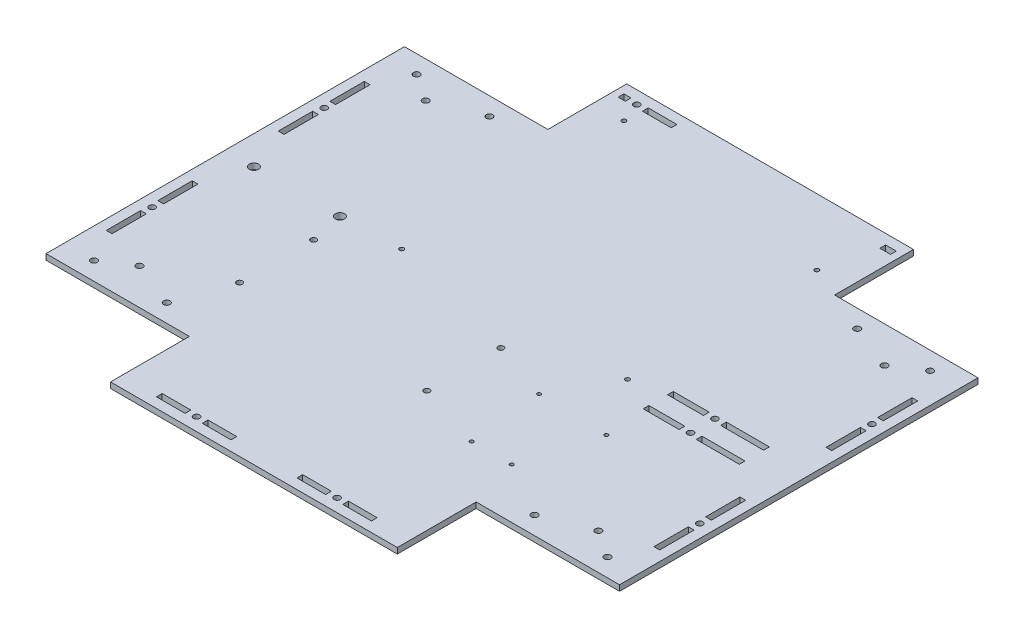
from build123d import *

# Parameters (mm, degrees)
SKETCH1_W                = 400
SKETCH1_H                = 360
BOSS_EXTRUDE1_DEPTH      = 4
SKETCH2_W                = 100
SKETCH2_H                = 55
CORNER_DEPTH             = 4
SKETCH3_R                = 2.25
MOTOR_MOUNTING_DEPTH     = 4
MIRROR2_COPY_1_SKETCH_W  = 100
MIRROR2_COPY_1_SKETCH_H  = 55
MIRROR2_COPY_1_DEPTH     = 4
MIRROR2_COPY_2_SKETCH_R  = 2.25
MIRROR2_COPY_2_DEPTH     = 4
PC_MOUNTING_REACH        = 6
SKETCH5_R                = 1.5
ARDUINO_MOUNTING_REACH   = 6
SKETCH6_R                = 1.25
DCDC_USB_MOUNTING_REACH  = 6
SKETCH7_R                = 2
SKETCH10_W               = 20
SKETCH10_H               = 4
SKETCH10_W_2             = 4
SKETCH10_H_2             = 24
SKETCH10_W_3             = 5
SKETCH10_W_4             = 7.47
SIDES_MOUNTING_DEPTH     = 5
SKETCH11_W               = 30
SKETCH11_H               = 4
SKETCH11_W_2             = 25
FIN_MOUNTING_DEPTH       = 5
M4_CLEARANCE_HOLE1_D     = 4.3
M4_CLEARANCE_HOLE1_DEPTH = 6
M4_CLEARANCE_HOLE1_TIP   = 1.291850331
M6_CLEARANCE_HOLE1_D     = 6.4
M6_CLEARANCE_HOLE1_DEPTH = 6
M6_CLEARANCE_HOLE1_TIP   = 1.922753981


with BuildPart() as part:
    # Sketch1 → Boss-Extrude1 (new body)
    with BuildSketch(Plane(origin=(0, 0, 0), x_dir=(1, 0, 0), z_dir=(0, 1, 0))):
        Rectangle(SKETCH1_W, SKETCH1_H)
    extrude(amount=BOSS_EXTRUDE1_DEPTH)

    # Sketch2 → Corner (cut)
    with BuildSketch(Plane(origin=(0, 4, 0), x_dir=(1, 0, 0), z_dir=(0, 1, 0))):
        with Locations((-150, 152.5)):
            Rectangle(SKETCH2_W, SKETCH2_H)
    corner = extrude(amount=-CORNER_DEPTH, mode=Mode.SUBTRACT)

    # Sketch3 → Motor mounting (cut)
    with BuildSketch(Plane(origin=(0, 4, 0), x_dir=(1, 0, 0), z_dir=(0, 1, 0))):
        with Locations((-179.05, 112.5)):
            Circle(SKETCH3_R)
        with Locations((-128.25, 112.5)):
            Circle(SKETCH3_R)
        with Locations((-160, 99.8)):
            Circle(SKETCH3_R)
    motor_mounting = extrude(amount=-MOTOR_MOUNTING_DEPTH, mode=Mode.SUBTRACT)

    # Mirror1: Corner, Motor mounting across plane
    add(corner.mirror(Plane.XY), mode=Mode.SUBTRACT)
    add(motor_mounting.mirror(Plane.XY), mode=Mode.SUBTRACT)

    # Mirror2: Corner, Motor mounting across plane
    add(corner.mirror(Plane(origin=(0, 0, 0), x_dir=(0, 0, 1), z_dir=(1, 0, 0))), mode=Mode.SUBTRACT)
    add(motor_mounting.mirror(Plane(origin=(0, 0, 0), x_dir=(0, 0, 1), z_dir=(1, 0, 0))), mode=Mode.SUBTRACT)

    # Mirror2 copy 1 sketch → Mirror2 copy 1 (cut)
    with BuildSketch(Plane(origin=(0, 4, 0), x_dir=(-1, 0, 0), z_dir=(0, 1, 0))):
        with Locations((-150, 152.5)):
            Rectangle(MIRROR2_COPY_1_SKETCH_W, MIRROR2_COPY_1_SKETCH_H)
    extrude(amount=-MIRROR2_COPY_1_DEPTH, mode=Mode.SUBTRACT)

    # Mirror2 copy 2 sketch → Mirror2 copy 2 (cut)
    with BuildSketch(Plane(origin=(0, 4, 0), x_dir=(-1, 0, 0), z_dir=(0, 1, 0))):
        with Locations((-179.05, 112.5)):
            Circle(MIRROR2_COPY_2_SKETCH_R)
        with Locations((-128.25, 112.5)):
            Circle(MIRROR2_COPY_2_SKETCH_R)
        with Locations((-160, 99.8)):
            Circle(MIRROR2_COPY_2_SKETCH_R)
    extrude(amount=-MIRROR2_COPY_2_DEPTH, mode=Mode.SUBTRACT)

    # Sketch5 → PC mounting (cut, up to next)
    with BuildSketch(Plane(origin=(0, 4, 0), x_dir=(1, 0, 0), z_dir=(0, 1, 0)), mode=Mode.PRIVATE) as pc_mounting_sk1:
        with Locations((-78.74, 156.73)):
            Circle(SKETCH5_R)
    pc_mounting_tool1 = extrude(pc_mounting_sk1.sketch, amount=-PC_MOUNTING_REACH, mode=Mode.PRIVATE) & part.part
    add(pc_mounting_tool1.solids().sort_by_distance((-78.74, 4, -156.73))[0], mode=Mode.SUBTRACT)
    # Sketch5 → PC mounting (cut, up to next)
    with BuildSketch(Plane(origin=(0, 4, 0), x_dir=(1, 0, 0), z_dir=(0, 1, 0)), mode=Mode.PRIVATE) as pc_mounting_sk2:
        with Locations((78.74, 133.87)):
            Circle(SKETCH5_R)
    pc_mounting_tool2 = extrude(pc_mounting_sk2.sketch, amount=-PC_MOUNTING_REACH, mode=Mode.PRIVATE) & part.part
    add(pc_mounting_tool2.solids().sort_by_distance((78.74, 4, -133.87))[0], mode=Mode.SUBTRACT)
    # Sketch5 → PC mounting (cut, up to next)
    with BuildSketch(Plane(origin=(0, 4, 0), x_dir=(1, 0, 0), z_dir=(0, 1, 0)), mode=Mode.PRIVATE) as pc_mounting_sk3:
        with Locations((-78.74, 1.79)):
            Circle(SKETCH5_R)
    pc_mounting_tool3 = extrude(pc_mounting_sk3.sketch, amount=-PC_MOUNTING_REACH, mode=Mode.PRIVATE) & part.part
    add(pc_mounting_tool3.solids().sort_by_distance((-78.74, 4, -1.79))[0], mode=Mode.SUBTRACT)
    # Sketch5 → PC mounting (cut, up to next)
    with BuildSketch(Plane(origin=(0, 4, 0), x_dir=(1, 0, 0), z_dir=(0, 1, 0)), mode=Mode.PRIVATE) as pc_mounting_sk4:
        with Locations((78.74, 1.79)):
            Circle(SKETCH5_R)
    pc_mounting_tool4 = extrude(pc_mounting_sk4.sketch, amount=-PC_MOUNTING_REACH, mode=Mode.PRIVATE) & part.part
    add(pc_mounting_tool4.solids().sort_by_distance((78.74, 4, -1.79))[0], mode=Mode.SUBTRACT)

    # Sketch6 → Arduino mounting (cut, up to next)
    with BuildSketch(Plane(origin=(0, 4, 0), x_dir=(1, 0, 0), z_dir=(0, 1, 0)), mode=Mode.PRIVATE) as arduino_mounting_sk1:
        with Locations((56.8, -37.9)):
            Circle(SKETCH6_R)
    arduino_mounting_tool1 = extrude(arduino_mounting_sk1.sketch, amount=-ARDUINO_MOUNTING_REACH, mode=Mode.PRIVATE) & part.part
    add(arduino_mounting_tool1.solids().sort_by_distance((56.8, 4, 37.9))[0], mode=Mode.SUBTRACT)
    # Sketch6 → Arduino mounting (cut, up to next)
    with BuildSketch(Plane(origin=(0, 4, 0), x_dir=(1, 0, 0), z_dir=(0, 1, 0)), mode=Mode.PRIVATE) as arduino_mounting_sk2:
        with Locations((105, -39.2)):
            Circle(SKETCH6_R)
    arduino_mounting_tool2 = extrude(arduino_mounting_sk2.sketch, amount=-ARDUINO_MOUNTING_REACH, mode=Mode.PRIVATE) & part.part
    add(arduino_mounting_tool2.solids().sort_by_distance((105, 4, 39.2))[0], mode=Mode.SUBTRACT)
    # Sketch6 → Arduino mounting (cut, up to next)
    with BuildSketch(Plane(origin=(0, 4, 0), x_dir=(1, 0, 0), z_dir=(0, 1, 0)), mode=Mode.PRIVATE) as arduino_mounting_sk3:
        with Locations((89.8, -90)):
            Circle(SKETCH6_R)
    arduino_mounting_tool3 = extrude(arduino_mounting_sk3.sketch, amount=-ARDUINO_MOUNTING_REACH, mode=Mode.PRIVATE) & part.part
    add(arduino_mounting_tool3.solids().sort_by_distance((89.8, 4, 90))[0], mode=Mode.SUBTRACT)
    # Sketch6 → Arduino mounting (cut, up to next)
    with BuildSketch(Plane(origin=(0, 4, 0), x_dir=(1, 0, 0), z_dir=(0, 1, 0)), mode=Mode.PRIVATE) as arduino_mounting_sk4:
        with Locations((61.9, -90)):
            Circle(SKETCH6_R)
    arduino_mounting_tool4 = extrude(arduino_mounting_sk4.sketch, amount=-ARDUINO_MOUNTING_REACH, mode=Mode.PRIVATE) & part.part
    add(arduino_mounting_tool4.solids().sort_by_distance((61.9, 4, 90))[0], mode=Mode.SUBTRACT)

    # Sketch7 → DCDC-USB mounting (cut, up to next)
    with BuildSketch(Plane(origin=(0, 4, 0), x_dir=(1, 0, 0), z_dir=(0, 1, 0)), mode=Mode.PRIVATE) as dcdc_usb_mounting_sk1:
        with Locations((-115, -75)):
            Circle(SKETCH7_R)
    dcdc_usb_mounting_tool1 = extrude(dcdc_usb_mounting_sk1.sketch, amount=-DCDC_USB_MOUNTING_REACH, mode=Mode.PRIVATE) & part.part
    add(dcdc_usb_mounting_tool1.solids().sort_by_distance((-115, 4, 75))[0], mode=Mode.SUBTRACT)
    # Sketch7 → DCDC-USB mounting (cut, up to next)
    with BuildSketch(Plane(origin=(0, 4, 0), x_dir=(1, 0, 0), z_dir=(0, 1, 0)), mode=Mode.PRIVATE) as dcdc_usb_mounting_sk2:
        with Locations((15.6, -75)):
            Circle(SKETCH7_R)
    dcdc_usb_mounting_tool2 = extrude(dcdc_usb_mounting_sk2.sketch, amount=-DCDC_USB_MOUNTING_REACH, mode=Mode.PRIVATE) & part.part
    add(dcdc_usb_mounting_tool2.solids().sort_by_distance((15.6, 4, 75))[0], mode=Mode.SUBTRACT)
    # Sketch7 → DCDC-USB mounting (cut, up to next)
    with BuildSketch(Plane(origin=(0, 4, 0), x_dir=(1, 0, 0), z_dir=(0, 1, 0)), mode=Mode.PRIVATE) as dcdc_usb_mounting_sk3:
        with Locations((-115, -23.4)):
            Circle(SKETCH7_R)
    dcdc_usb_mounting_tool3 = extrude(dcdc_usb_mounting_sk3.sketch, amount=-DCDC_USB_MOUNTING_REACH, mode=Mode.PRIVATE) & part.part
    add(dcdc_usb_mounting_tool3.solids().sort_by_distance((-115, 4, 23.4))[0], mode=Mode.SUBTRACT)
    # Sketch7 → DCDC-USB mounting (cut, up to next)
    with BuildSketch(Plane(origin=(0, 4, 0), x_dir=(1, 0, 0), z_dir=(0, 1, 0)), mode=Mode.PRIVATE) as dcdc_usb_mounting_sk4:
        with Locations((15.6, -23.4)):
            Circle(SKETCH7_R)
    dcdc_usb_mounting_tool4 = extrude(dcdc_usb_mounting_sk4.sketch, amount=-DCDC_USB_MOUNTING_REACH, mode=Mode.PRIVATE) & part.part
    add(dcdc_usb_mounting_tool4.solids().sort_by_distance((15.6, 4, 23.4))[0], mode=Mode.SUBTRACT)

    # Sketch10 → Sides mounting (cut, through all)
    with BuildSketch(Plane(origin=(0, 4, 0), x_dir=(1, 0, 0), z_dir=(0, 1, 0))):
        with Locations((-68, 171)):
            Rectangle(SKETCH10_W, SKETCH10_H)
        with Locations((-191, 78)):
            Rectangle(SKETCH10_W_2, SKETCH10_H_2)
        with Locations((-191, -42)):
            Rectangle(SKETCH10_W_2, SKETCH10_H_2)
        with Locations((-191, -78)):
            Rectangle(SKETCH10_W_2, SKETCH10_H_2)
        with Locations((-191, 42)):
            Rectangle(SKETCH10_W_2, SKETCH10_H_2)
        with Locations((191, 78)):
            Rectangle(SKETCH10_W_2, SKETCH10_H_2)
        with Locations((191, 42)):
            Rectangle(SKETCH10_W_2, SKETCH10_H_2)
        with Locations((191, -42)):
            Rectangle(SKETCH10_W_2, SKETCH10_H_2)
        with Locations((191, -78)):
            Rectangle(SKETCH10_W_2, SKETCH10_H_2)
        with Locations((-65, -171)):
            Rectangle(SKETCH10_W, SKETCH10_H)
        with Locations((-33, -171)):
            Rectangle(SKETCH10_W, SKETCH10_H)
        with Locations((33, -171)):
            Rectangle(SKETCH10_W, SKETCH10_H)
        with Locations((65, -171)):
            Rectangle(SKETCH10_W, SKETCH10_H)
        with Locations((-92.5, 171)):
            Rectangle(SKETCH10_W_3, SKETCH10_H)
        with Locations((91.265, 171)):
            Rectangle(SKETCH10_W_4, SKETCH10_H)
    extrude(amount=-SIDES_MOUNTING_DEPTH, mode=Mode.SUBTRACT)

    # Sketch11 → fin mounting (cut, through all)
    with BuildSketch(Plane(origin=(0, 4, 0), x_dir=(1, 0, 0), z_dir=(0, 1, 0))):
        with Locations((154, 8.5)):
            Rectangle(SKETCH11_W, SKETCH11_H)
        with Locations((114.5, 8.5)):
            Rectangle(SKETCH11_W_2, SKETCH11_H)
        with Locations((114.5, -8.5)):
            Rectangle(SKETCH11_W_2, SKETCH11_H)
        with Locations((154, -8.5)):
            Rectangle(SKETCH11_W, SKETCH11_H)
    extrude(amount=-FIN_MOUNTING_DEPTH, mode=Mode.SUBTRACT)

    # M4 Clearance Hole1
    with Locations(Plane(origin=(0, 4, 0), x_dir=(-1, 0, 0), z_dir=(0, 1, 0))):
        with Locations((49, 171), (-49, 171), (191, 60), (191, -60), (-133, -8.5), (-191, -60), (-191, 60), (84, -171), (-133, 8.5)):
            Hole(M4_CLEARANCE_HOLE1_D / 2, depth=M4_CLEARANCE_HOLE1_DEPTH)
            with Locations((0, 0, -(M4_CLEARANCE_HOLE1_DEPTH + M4_CLEARANCE_HOLE1_TIP / 2))):  # 118° drill point
                Cone(0, M4_CLEARANCE_HOLE1_D / 2, M4_CLEARANCE_HOLE1_TIP, mode=Mode.SUBTRACT)

    # M6 Clearance Hole1
    with Locations(Plane(origin=(0, 4, 0), x_dir=(-1, 0, 0), z_dir=(0, 1, 0))):
        with Locations((180, 0), (120, 0)):
            Hole(M6_CLEARANCE_HOLE1_D / 2, depth=M6_CLEARANCE_HOLE1_DEPTH)
            with Locations((0, 0, -(M6_CLEARANCE_HOLE1_DEPTH + M6_CLEARANCE_HOLE1_TIP / 2))):  # 118° drill point
                Cone(0, M6_CLEARANCE_HOLE1_D / 2, M6_CLEARANCE_HOLE1_TIP, mode=Mode.SUBTRACT)


solid = part.part
